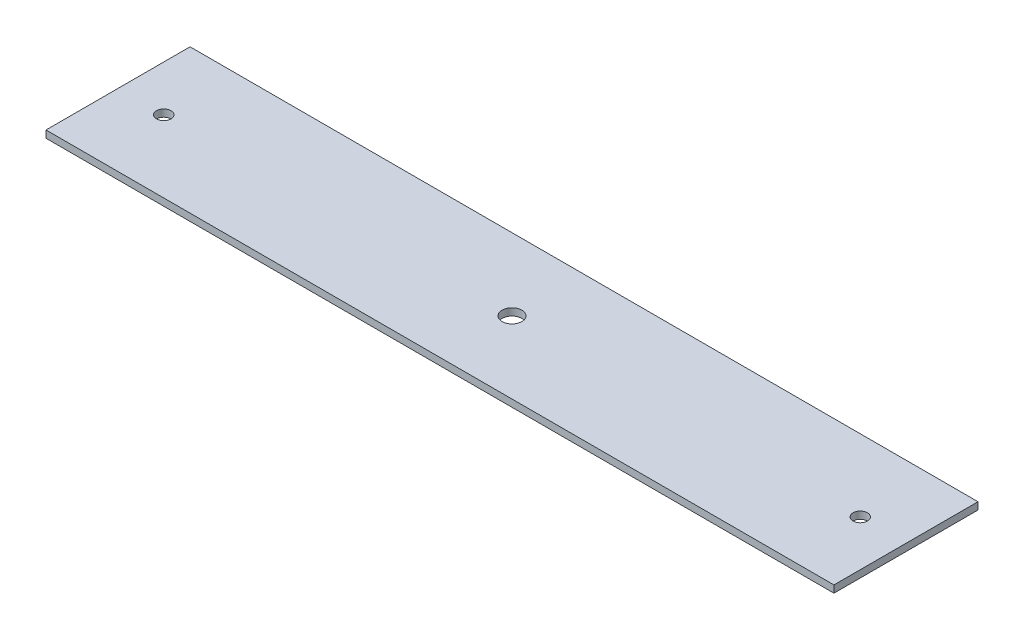
from build123d import *

# Parameters (mm, degrees)
SKETCH1_W           = 437.6
SKETCH1_H           = 80
SKETCH1_R           = 5.5
SKETCH1_R_2         = 4
BOSS_EXTRUDE1_DEPTH = 4


with BuildPart() as part:
    # Sketch1 → Boss-Extrude1 (new body)
    with BuildSketch(Plane(origin=(0, 0, 0), x_dir=(1, 0, 0), z_dir=(0, 1, 0))):
        Rectangle(SKETCH1_W, SKETCH1_H)
        Circle(SKETCH1_R, mode=Mode.SUBTRACT)
        with Locations((-193.4, 0)):
            Circle(SKETCH1_R_2, mode=Mode.SUBTRACT)
        with Locations((193.4, 0)):
            Circle(SKETCH1_R_2, mode=Mode.SUBTRACT)
    extrude(amount=BOSS_EXTRUDE1_DEPTH)


solid = part.part
